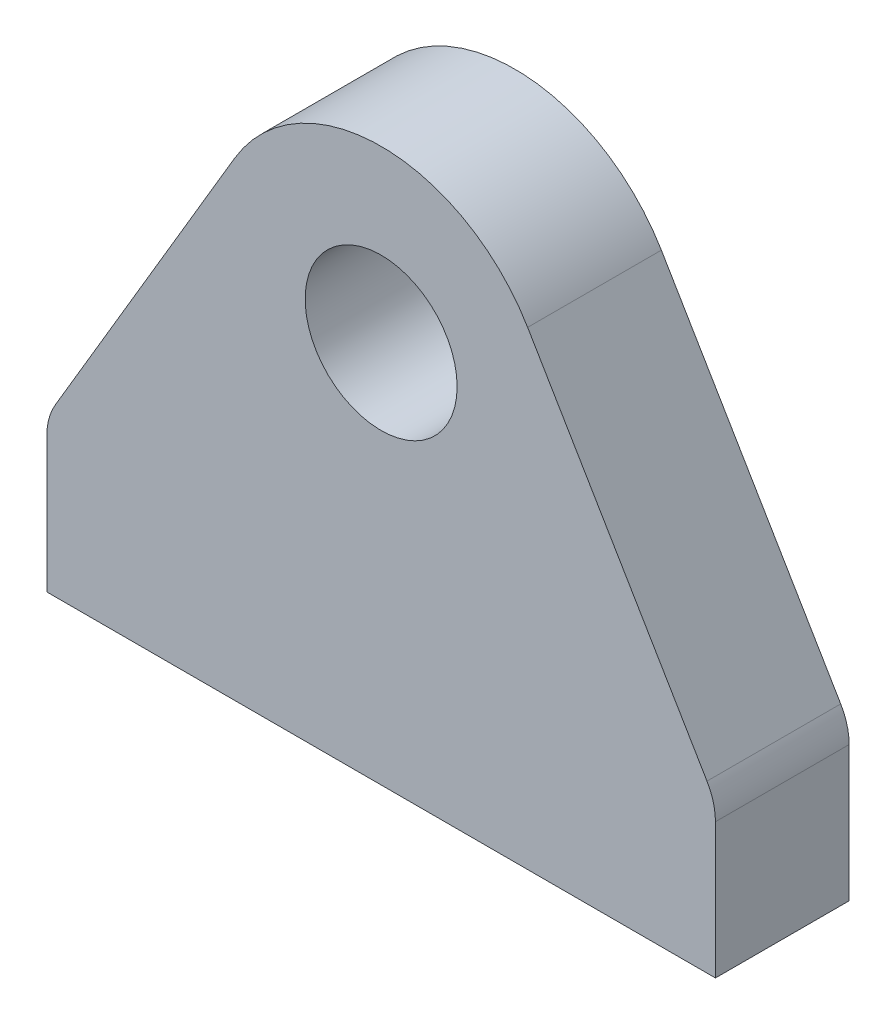
from build123d import *

# Parameters (mm, degrees)
SKETCH1_R           = 12.5
BOSS_EXTRUDE1_DEPTH = 11
BOSS_EXTRUDE2_DEPTH = 22
FILLET1_R           = 10


with BuildPart() as part:
    # Sketch1 → Boss-Extrude1 (new body, symmetric)
    with BuildSketch(Plane.XY):
        with BuildLine():
            Line((-55, 0), (55, 0))
            Line((55, 0), (55, 25))
            Line((55, 25), (28, 25))
            Line((28, 25), (28, 63))
            ThreePointArc((28, 63), (0, 91), (-28, 63))
            Line((-28, 63), (-28, 25))
            Line((-28, 25), (-55, 25))
            Line((-55, 25), (-55, 0))
        make_face()
        with Locations((0, 63)):
            Circle(SKETCH1_R, mode=Mode.SUBTRACT)
    extrude(amount=BOSS_EXTRUDE1_DEPTH, both=True)

    # Sketch2 → Boss-Extrude2 (add)
    with BuildSketch(Plane.XY.offset(11)):
        with BuildLine():
            Line((-55, 25), (-24.101425307, 77.252062944))
            ThreePointArc((-24.101425307, 77.252062944), (-27.007775812, 70.38783092), (-28, 63))
            Line((-28, 63), (-28, 25))
            Line((-28, 25), (-55, 25))
        make_face()
        with BuildLine():
            Line((55, 25), (24.101425307, 77.252062944))
            ThreePointArc((24.101425307, 77.252062944), (27.007775812, 70.38783092), (28, 63))
            Line((28, 63), (28, 25))
            Line((28, 25), (55, 25))
        make_face()
    extrude(amount=-BOSS_EXTRUDE2_DEPTH)

    # Fillet1
    fillet1_edges = [part.edges().sort_by_distance(p)[0] for p in [
        (-55, 25, 0),
        (55, 25, 0),
    ]]
    fillet(fillet1_edges, radius=FILLET1_R)


solid = part.part
